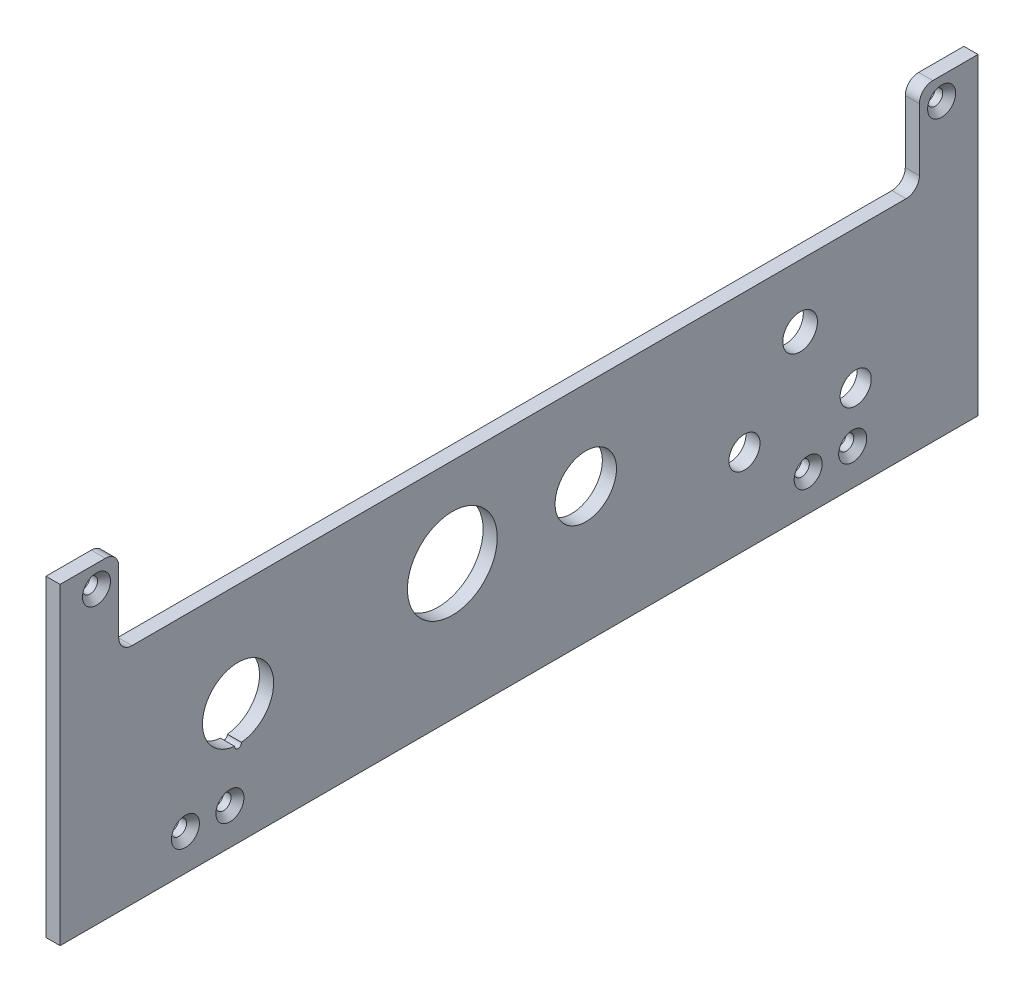
from build123d import *

# Parameters (mm, degrees)
BOSS_EXTRUDE1_DEPTH                             = 3.175
CSK_FOR_M3_FLAT_HEAD_MACHINE_SCREW1_D           = 3.4
CSK_FOR_M3_FLAT_HEAD_MACHINE_SCREW1_CSINK_D     = 6.3
CSK_FOR_M3_FLAT_HEAD_MACHINE_SCREW1_CSINK_ANGLE = 90
SKETCH4_R                                       = 6.9
SKETCH4_R_2                                     = 3.9
SKETCH4_R_3                                     = 3.5
SKETCH4_R_4                                     = 10.1
CUT_EXTRUDE1_DEPTH                              = 4.175


with BuildPart() as part:
    # Sketch1 → Boss-Extrude1 (new body)
    with BuildSketch(Plane(origin=(0, 0, 0), x_dir=(0, 0, -1), z_dir=(1, 0, 0))):
        with BuildLine():
            Line((103.175, 0), (103.175, 3.175))
            Line((103.175, 3.175), (103.175, 47.175))
            Line((103.175, 47.175), (103.175, 50.35))
            Line((103.175, 50.35), (103.175, 70.35))
            Line((103.175, 70.35), (93, 70.35))
            ThreePointArc((93, 70.35), (90.878679656, 69.471320344), (90, 67.35))
            Line((90, 67.35), (90, 53.35))
            ThreePointArc((90, 53.35), (89.121320344, 51.228679656), (87, 50.35))
            Line((87, 50.35), (-87, 50.35))
            ThreePointArc((-87, 50.35), (-89.121320344, 51.228679656), (-90, 53.35))
            Line((-90, 53.35), (-90, 67.35))
            ThreePointArc((-90, 67.35), (-90.878679656, 69.471320344), (-93, 70.35))
            Line((-93, 70.35), (-103.175, 70.35))
            Line((-103.175, 70.35), (-103.175, 50.35))
            Line((-103.175, 50.35), (-103.175, 47.175))
            Line((-103.175, 47.175), (-103.175, 3.175))
            Line((-103.175, 3.175), (-103.175, 0))
            Line((-103.175, 0), (103.175, 0))
        make_face()
    extrude(amount=BOSS_EXTRUDE1_DEPTH)

    # CSK for M3 Flat Head Machine Screw1 (through all)
    with Locations(Plane(origin=(3.175, 0, 0), x_dir=(0, 0, -1), z_dir=(1, 0, 0))):
        with Locations((-75, 8.175), (-65, 8.175), (-95, 65.35)):
            csk_for_m3_flat_head_machine_screw1 = CounterSinkHole(CSK_FOR_M3_FLAT_HEAD_MACHINE_SCREW1_D / 2, CSK_FOR_M3_FLAT_HEAD_MACHINE_SCREW1_CSINK_D / 2, counter_sink_angle=CSK_FOR_M3_FLAT_HEAD_MACHINE_SCREW1_CSINK_ANGLE)

    # Mirror1: CSK for M3 Flat Head Machine Screw1 across plane
    add(csk_for_m3_flat_head_machine_screw1.mirror(Plane.XY), mode=Mode.SUBTRACT)

    # Sketch4 → Cut-Extrude1 (cut, through all)
    with BuildSketch(Plane(origin=(3.175, 0, 0), x_dir=(0, 0, -1), z_dir=(1, 0, 0))):
        with Locations((15, 30.35)):
            Circle(SKETCH4_R)
        with Locations((63.175, 36.35)):
            Circle(SKETCH4_R_2)
        with Locations((50.675, 19.175)):
            Circle(SKETCH4_R_3)
        with Locations((75.675, 19.175)):
            Circle(SKETCH4_R_3)
        with Locations((-15, 30.35)):
            Circle(SKETCH4_R_4)
        with BuildLine():
            ThreePointArc((-62.400909683, 19.212539062), (-63.175, 35.175), (-63.949090317, 19.212539062))
            ThreePointArc((-63.949090317, 19.212539062), (-63.175, 18.4), (-62.400909683, 19.212539062))
        make_face()
    extrude(amount=-CUT_EXTRUDE1_DEPTH, mode=Mode.SUBTRACT)


solid = part.part
